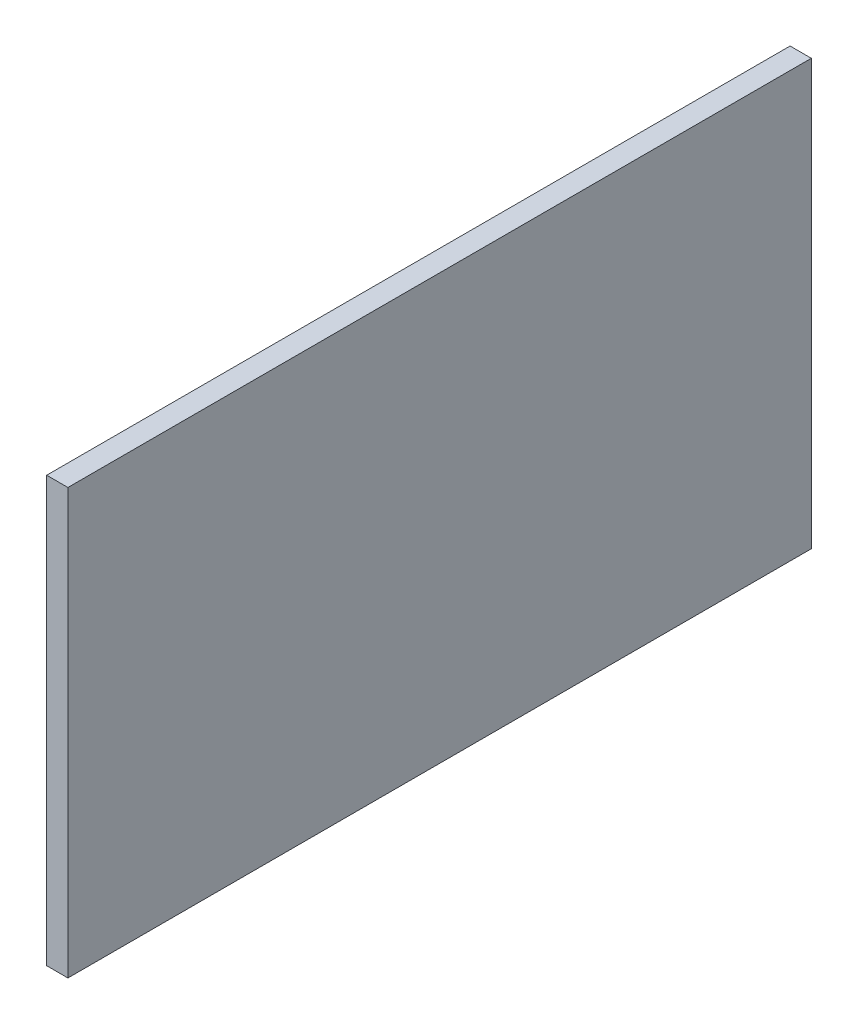
from build123d import *

# Parameters (mm, degrees)
SKICA1_W               = 350
SKICA1_H               = 200
VYSUNOUT1_DEPTH        = 10
SKICA2_R               = 15
VYSUNOUT2_DEPTH        = 5
ZAOBLIT1_R             = 1.5
LINPOLE1_COUNT         = 2
LINPOLE1_PITCH         = 280
LINPOLE1_COUNT_DIR2    = 2
LINPOLE1_PITCH_DIR2    = 150
ZAOBLIT1_OF_LINPOLE1_R = 1.5


with BuildPart() as part:
    # Skica1 → Vysunout1 (new body)
    with BuildSketch(Plane(origin=(0, 0, 0), x_dir=(0, 0, -1), z_dir=(1, 0, 0))):
        Rectangle(SKICA1_W, SKICA1_H)
    extrude(amount=VYSUNOUT1_DEPTH)

    # Skica2 → Vysunout2 (add)
    with BuildSketch(Plane.ZY):
        with Locations((-140, 75)):
            Circle(SKICA2_R)
    vysunout2 = extrude(amount=VYSUNOUT2_DEPTH)

    # Zaoblit1
    zaoblit1_edges = [part.edges().sort_by_distance(p)[0] for p in [
        (-5, 75, -155),
    ]]
    fillet(zaoblit1_edges, radius=ZAOBLIT1_R)

    # LinPole1: Vysunout2 2 × 2
    with Locations(*[(0, -j * LINPOLE1_PITCH_DIR2, i * LINPOLE1_PITCH) for i in range(LINPOLE1_COUNT) for j in range(LINPOLE1_COUNT_DIR2) if (i, j) != (0, 0)]):
        add(vysunout2)

    # Zaoblit1 of LinPole1
    zaoblit1_of_linpole1_edges = [part.edges().sort_by_distance(p)[0] for p in [
        (-5, -75, -155),
        (-5, 75, 125),
        (-5, -75, 125),
    ]]
    fillet(zaoblit1_of_linpole1_edges, radius=ZAOBLIT1_OF_LINPOLE1_R)


solid = part.part
